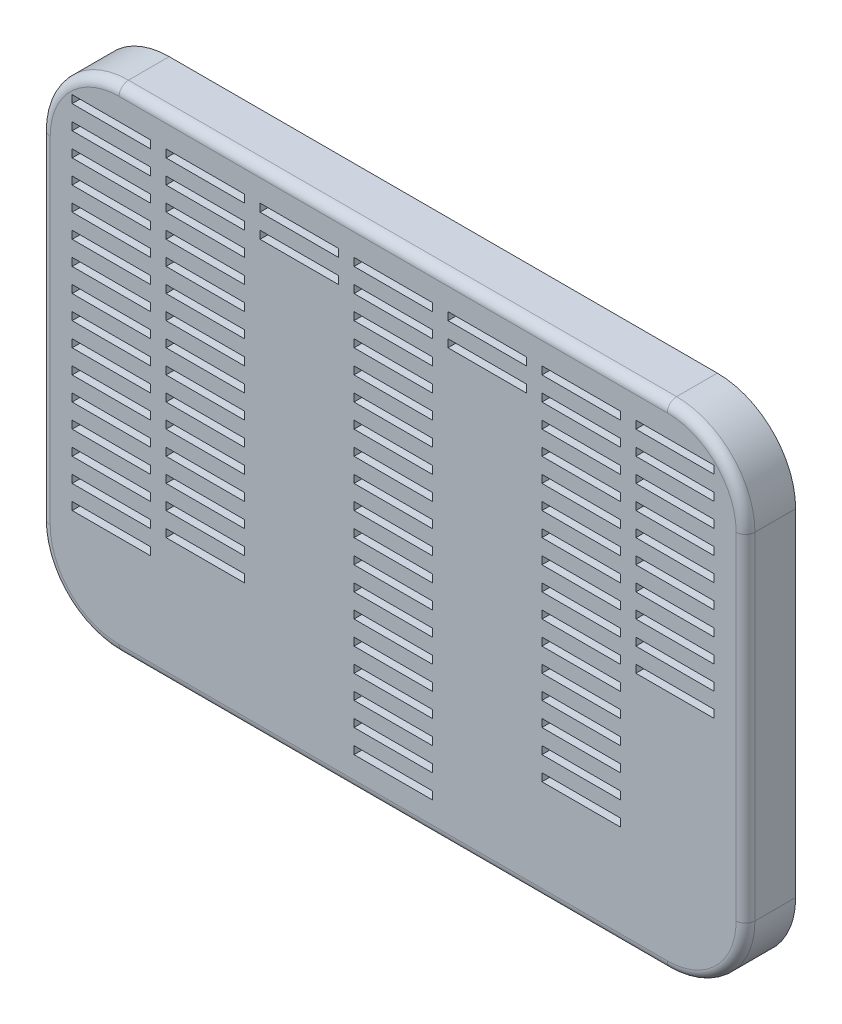
from build123d import *

# Parameters (mm, degrees)
SKETCH1_W           = 225
SKETCH1_H           = 157.5
BOSS_EXTRUDE1_DEPTH = 2
SKETCH1_3_W         = 225
SKETCH1_3_H         = 157.5
SKETCH1_3_W_2       = 25
SKETCH1_3_H_2       = 2.5
BOSS_EXTRUDE2_DEPTH = 16
FILLET1_R           = 25
FILLET2_R           = 3


with BuildPart() as part:
    # Sketch1 → Boss-Extrude1 (new body)
    with BuildSketch(Plane.XY):
        with Locations((39.862204724, -7.470563517)):
            Rectangle(SKETCH1_W, SKETCH1_H)
    extrude(amount=BOSS_EXTRUDE1_DEPTH)

    # Sketch1_3 → Boss-Extrude2 (add)
    with BuildSketch(Plane.XY):
        with Locations((39.862204724, -7.470563517)):
            Rectangle(SKETCH1_3_W, SKETCH1_3_H)
        with Locations((-50.137795276, -52.470563517)):
            Rectangle(SKETCH1_3_W_2, SKETCH1_3_H_2, mode=Mode.SUBTRACT)
        with Locations((39.862204724, -74.970563517)):
            Rectangle(SKETCH1_3_W_2, SKETCH1_3_H_2, mode=Mode.SUBTRACT)
        with Locations((39.862204724, -67.470563517)):
            Rectangle(SKETCH1_3_W_2, SKETCH1_3_H_2, mode=Mode.SUBTRACT)
        with Locations((39.862204724, -59.970563517)):
            Rectangle(SKETCH1_3_W_2, SKETCH1_3_H_2, mode=Mode.SUBTRACT)
        with Locations((39.862204724, -52.470563517)):
            Rectangle(SKETCH1_3_W_2, SKETCH1_3_H_2, mode=Mode.SUBTRACT)
        with Locations((-50.137795276, -44.970563517)):
            Rectangle(SKETCH1_3_W_2, SKETCH1_3_H_2, mode=Mode.SUBTRACT)
        with Locations((-50.137795276, -37.470563517)):
            Rectangle(SKETCH1_3_W_2, SKETCH1_3_H_2, mode=Mode.SUBTRACT)
        with Locations((-50.137795276, -29.970563517)):
            Rectangle(SKETCH1_3_W_2, SKETCH1_3_H_2, mode=Mode.SUBTRACT)
        with Locations((-20.137795276, -44.970563517)):
            Rectangle(SKETCH1_3_W_2, SKETCH1_3_H_2, mode=Mode.SUBTRACT)
        with Locations((-20.137795276, -37.470563517)):
            Rectangle(SKETCH1_3_W_2, SKETCH1_3_H_2, mode=Mode.SUBTRACT)
        with Locations((-20.137795276, -29.970563517)):
            Rectangle(SKETCH1_3_W_2, SKETCH1_3_H_2, mode=Mode.SUBTRACT)
        with Locations((-50.137795276, -22.470563517)):
            Rectangle(SKETCH1_3_W_2, SKETCH1_3_H_2, mode=Mode.SUBTRACT)
        with Locations((-50.137795276, -14.970563517)):
            Rectangle(SKETCH1_3_W_2, SKETCH1_3_H_2, mode=Mode.SUBTRACT)
        with Locations((-50.137795276, -7.470563517)):
            Rectangle(SKETCH1_3_W_2, SKETCH1_3_H_2, mode=Mode.SUBTRACT)
        with Locations((-20.137795276, -22.470563517)):
            Rectangle(SKETCH1_3_W_2, SKETCH1_3_H_2, mode=Mode.SUBTRACT)
        with Locations((-20.137795276, -14.970563517)):
            Rectangle(SKETCH1_3_W_2, SKETCH1_3_H_2, mode=Mode.SUBTRACT)
        with Locations((-20.137795276, -7.470563517)):
            Rectangle(SKETCH1_3_W_2, SKETCH1_3_H_2, mode=Mode.SUBTRACT)
        with Locations((39.862204724, -44.970563517)):
            Rectangle(SKETCH1_3_W_2, SKETCH1_3_H_2, mode=Mode.SUBTRACT)
        with Locations((39.862204724, -37.470563517)):
            Rectangle(SKETCH1_3_W_2, SKETCH1_3_H_2, mode=Mode.SUBTRACT)
        with Locations((39.862204724, -29.970563517)):
            Rectangle(SKETCH1_3_W_2, SKETCH1_3_H_2, mode=Mode.SUBTRACT)
        with Locations((39.862204724, -22.470563517)):
            Rectangle(SKETCH1_3_W_2, SKETCH1_3_H_2, mode=Mode.SUBTRACT)
        with Locations((39.862204724, -14.970563517)):
            Rectangle(SKETCH1_3_W_2, SKETCH1_3_H_2, mode=Mode.SUBTRACT)
        with Locations((39.862204724, -7.470563517)):
            Rectangle(SKETCH1_3_W_2, SKETCH1_3_H_2, mode=Mode.SUBTRACT)
        with Locations((99.862204724, -52.470563517)):
            Rectangle(SKETCH1_3_W_2, SKETCH1_3_H_2, mode=Mode.SUBTRACT)
        with Locations((99.862204724, -44.970563517)):
            Rectangle(SKETCH1_3_W_2, SKETCH1_3_H_2, mode=Mode.SUBTRACT)
        with Locations((99.862204724, -37.470563517)):
            Rectangle(SKETCH1_3_W_2, SKETCH1_3_H_2, mode=Mode.SUBTRACT)
        with Locations((99.862204724, -29.970563517)):
            Rectangle(SKETCH1_3_W_2, SKETCH1_3_H_2, mode=Mode.SUBTRACT)
        with Locations((99.862204724, -22.470563517)):
            Rectangle(SKETCH1_3_W_2, SKETCH1_3_H_2, mode=Mode.SUBTRACT)
        with Locations((99.862204724, -14.970563517)):
            Rectangle(SKETCH1_3_W_2, SKETCH1_3_H_2, mode=Mode.SUBTRACT)
        with Locations((99.862204724, -7.470563517)):
            Rectangle(SKETCH1_3_W_2, SKETCH1_3_H_2, mode=Mode.SUBTRACT)
        with Locations((129.862204724, -7.470563517)):
            Rectangle(SKETCH1_3_W_2, SKETCH1_3_H_2, mode=Mode.SUBTRACT)
        with Locations((-50.137795276, 0.029436483)):
            Rectangle(SKETCH1_3_W_2, SKETCH1_3_H_2, mode=Mode.SUBTRACT)
        with Locations((-50.137795276, 7.529436483)):
            Rectangle(SKETCH1_3_W_2, SKETCH1_3_H_2, mode=Mode.SUBTRACT)
        with Locations((-20.137795276, 0.029436483)):
            Rectangle(SKETCH1_3_W_2, SKETCH1_3_H_2, mode=Mode.SUBTRACT)
        with Locations((-20.137795276, 7.529436483)):
            Rectangle(SKETCH1_3_W_2, SKETCH1_3_H_2, mode=Mode.SUBTRACT)
        with Locations((-50.137795276, 15.029436483)):
            Rectangle(SKETCH1_3_W_2, SKETCH1_3_H_2, mode=Mode.SUBTRACT)
        with Locations((-50.137795276, 22.529436483)):
            Rectangle(SKETCH1_3_W_2, SKETCH1_3_H_2, mode=Mode.SUBTRACT)
        with Locations((-50.137795276, 30.029436483)):
            Rectangle(SKETCH1_3_W_2, SKETCH1_3_H_2, mode=Mode.SUBTRACT)
        with Locations((-20.137795276, 15.029436483)):
            Rectangle(SKETCH1_3_W_2, SKETCH1_3_H_2, mode=Mode.SUBTRACT)
        with Locations((-20.137795276, 22.529436483)):
            Rectangle(SKETCH1_3_W_2, SKETCH1_3_H_2, mode=Mode.SUBTRACT)
        with Locations((-20.137795276, 30.029436483)):
            Rectangle(SKETCH1_3_W_2, SKETCH1_3_H_2, mode=Mode.SUBTRACT)
        with Locations((39.862204724, 0.029436483)):
            Rectangle(SKETCH1_3_W_2, SKETCH1_3_H_2, mode=Mode.SUBTRACT)
        with Locations((39.862204724, 7.529436483)):
            Rectangle(SKETCH1_3_W_2, SKETCH1_3_H_2, mode=Mode.SUBTRACT)
        with Locations((39.862204724, 15.029436483)):
            Rectangle(SKETCH1_3_W_2, SKETCH1_3_H_2, mode=Mode.SUBTRACT)
        with Locations((39.862204724, 22.529436483)):
            Rectangle(SKETCH1_3_W_2, SKETCH1_3_H_2, mode=Mode.SUBTRACT)
        with Locations((39.862204724, 30.029436483)):
            Rectangle(SKETCH1_3_W_2, SKETCH1_3_H_2, mode=Mode.SUBTRACT)
        with Locations((-50.137795276, 37.529436483)):
            Rectangle(SKETCH1_3_W_2, SKETCH1_3_H_2, mode=Mode.SUBTRACT)
        with Locations((-50.137795276, 45.029436483)):
            Rectangle(SKETCH1_3_W_2, SKETCH1_3_H_2, mode=Mode.SUBTRACT)
        with Locations((-20.137795276, 37.529436483)):
            Rectangle(SKETCH1_3_W_2, SKETCH1_3_H_2, mode=Mode.SUBTRACT)
        with Locations((-20.137795276, 45.029436483)):
            Rectangle(SKETCH1_3_W_2, SKETCH1_3_H_2, mode=Mode.SUBTRACT)
        with Locations((-50.137795276, 52.529436483)):
            Rectangle(SKETCH1_3_W_2, SKETCH1_3_H_2, mode=Mode.SUBTRACT)
        with Locations((-50.137795276, 60.029436483)):
            Rectangle(SKETCH1_3_W_2, SKETCH1_3_H_2, mode=Mode.SUBTRACT)
        with Locations((-20.137795276, 52.529436483)):
            Rectangle(SKETCH1_3_W_2, SKETCH1_3_H_2, mode=Mode.SUBTRACT)
        with Locations((-20.137795276, 60.029436483)):
            Rectangle(SKETCH1_3_W_2, SKETCH1_3_H_2, mode=Mode.SUBTRACT)
        with Locations((39.862204724, 37.529436483)):
            Rectangle(SKETCH1_3_W_2, SKETCH1_3_H_2, mode=Mode.SUBTRACT)
        with Locations((39.862204724, 45.029436483)):
            Rectangle(SKETCH1_3_W_2, SKETCH1_3_H_2, mode=Mode.SUBTRACT)
        with Locations((9.862204724, 52.529436483)):
            Rectangle(SKETCH1_3_W_2, SKETCH1_3_H_2, mode=Mode.SUBTRACT)
        with Locations((9.862204724, 60.029436483)):
            Rectangle(SKETCH1_3_W_2, SKETCH1_3_H_2, mode=Mode.SUBTRACT)
        with Locations((39.862204724, 52.529436483)):
            Rectangle(SKETCH1_3_W_2, SKETCH1_3_H_2, mode=Mode.SUBTRACT)
        with Locations((39.862204724, 60.029436483)):
            Rectangle(SKETCH1_3_W_2, SKETCH1_3_H_2, mode=Mode.SUBTRACT)
        with Locations((99.862204724, 0.029436483)):
            Rectangle(SKETCH1_3_W_2, SKETCH1_3_H_2, mode=Mode.SUBTRACT)
        with Locations((99.862204724, 7.529436483)):
            Rectangle(SKETCH1_3_W_2, SKETCH1_3_H_2, mode=Mode.SUBTRACT)
        with Locations((129.862204724, 0.029436483)):
            Rectangle(SKETCH1_3_W_2, SKETCH1_3_H_2, mode=Mode.SUBTRACT)
        with Locations((129.862204724, 7.529436483)):
            Rectangle(SKETCH1_3_W_2, SKETCH1_3_H_2, mode=Mode.SUBTRACT)
        with Locations((99.862204724, 15.029436483)):
            Rectangle(SKETCH1_3_W_2, SKETCH1_3_H_2, mode=Mode.SUBTRACT)
        with Locations((99.862204724, 22.529436483)):
            Rectangle(SKETCH1_3_W_2, SKETCH1_3_H_2, mode=Mode.SUBTRACT)
        with Locations((99.862204724, 30.029436483)):
            Rectangle(SKETCH1_3_W_2, SKETCH1_3_H_2, mode=Mode.SUBTRACT)
        with Locations((129.862204724, 15.029436483)):
            Rectangle(SKETCH1_3_W_2, SKETCH1_3_H_2, mode=Mode.SUBTRACT)
        with Locations((129.862204724, 22.529436483)):
            Rectangle(SKETCH1_3_W_2, SKETCH1_3_H_2, mode=Mode.SUBTRACT)
        with Locations((129.862204724, 30.029436483)):
            Rectangle(SKETCH1_3_W_2, SKETCH1_3_H_2, mode=Mode.SUBTRACT)
        with Locations((69.862204724, 52.529436483)):
            Rectangle(SKETCH1_3_W_2, SKETCH1_3_H_2, mode=Mode.SUBTRACT)
        with Locations((69.862204724, 60.029436483)):
            Rectangle(SKETCH1_3_W_2, SKETCH1_3_H_2, mode=Mode.SUBTRACT)
        with Locations((99.862204724, 37.529436483)):
            Rectangle(SKETCH1_3_W_2, SKETCH1_3_H_2, mode=Mode.SUBTRACT)
        with Locations((99.862204724, 45.029436483)):
            Rectangle(SKETCH1_3_W_2, SKETCH1_3_H_2, mode=Mode.SUBTRACT)
        with Locations((129.862204724, 37.529436483)):
            Rectangle(SKETCH1_3_W_2, SKETCH1_3_H_2, mode=Mode.SUBTRACT)
        with Locations((129.862204724, 45.029436483)):
            Rectangle(SKETCH1_3_W_2, SKETCH1_3_H_2, mode=Mode.SUBTRACT)
        with Locations((99.862204724, 52.529436483)):
            Rectangle(SKETCH1_3_W_2, SKETCH1_3_H_2, mode=Mode.SUBTRACT)
        with Locations((99.862204724, 60.029436483)):
            Rectangle(SKETCH1_3_W_2, SKETCH1_3_H_2, mode=Mode.SUBTRACT)
        with Locations((129.862204724, 52.529436483)):
            Rectangle(SKETCH1_3_W_2, SKETCH1_3_H_2, mode=Mode.SUBTRACT)
        with Locations((129.862204724, 60.029436483)):
            Rectangle(SKETCH1_3_W_2, SKETCH1_3_H_2, mode=Mode.SUBTRACT)
    extrude(amount=BOSS_EXTRUDE2_DEPTH)

    # Fillet1
    fillet1_edges = [part.edges().sort_by_distance(p)[0] for p in [
        (-72.637795276, 71.279436483, 8),
        (-72.637795276, -86.220563517, 8),
        (152.362204724, -86.220563517, 8),
        (152.362204724, 71.279436483, 8),
    ]]
    fillet(fillet1_edges, radius=FILLET1_R)

    # Fillet2
    fillet2_edges = [part.edges().sort_by_distance(p)[0] for p in [
        (-65.315464805, 63.957106012, 16),
        (-72.637795276, -7.470563517, 16),
        (-65.315464805, -78.898233047, 16),
        (39.862204724, -86.220563517, 16),
        (145.039874254, -78.898233047, 16),
        (152.362204724, -7.470563517, 16),
        (145.039874254, 63.957106012, 16),
        (39.862204724, 71.279436483, 16),
    ]]
    fillet(fillet2_edges, radius=FILLET2_R)


solid = part.part
